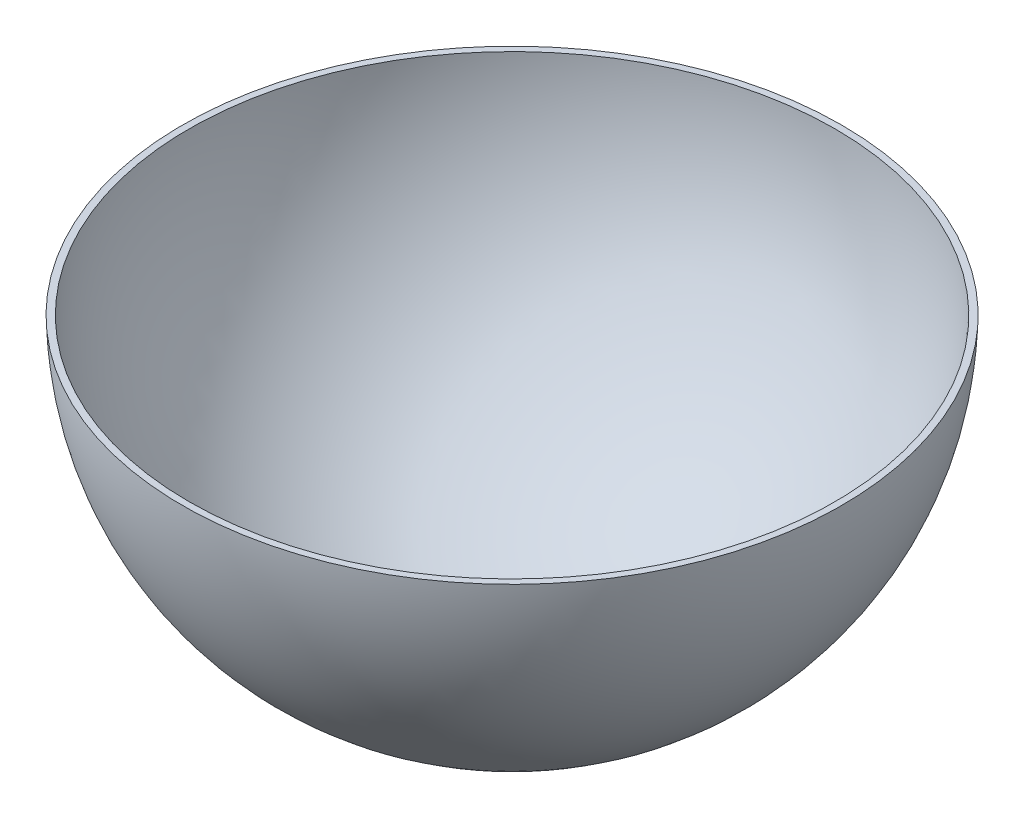
from build123d import *

# Parameters (mm, degrees)
SKETCH2_W               = 329.482175278
SKETCH2_H               = 165.618230588
CUT_EXTRUDE1_DEPTH      = 126
CUT_EXTRUDE1_DEPTH_BACK = 126


with BuildPart() as part:
    # Sketch1 one side → Revolve1 (revolve)
    with BuildSketch(Plane(origin=(0, 0, 0), x_dir=(0, 0, -1), z_dir=(1, 0, 0))):
        with BuildLine():
            ThreePointArc((0, -125), (88.388347648, -88.388347648), (125, 0))
            ThreePointArc((125, 0), (88.388347648, 88.388347648), (0, 125))
            Line((0, 125), (0, 122.5))
            ThreePointArc((0, 122.5), (86.620580695, 86.620580695), (122.5, 0))
            ThreePointArc((122.5, 0), (86.620580695, -86.620580695), (0, -122.5))
            Line((0, -122.5), (0, -125))
        make_face()
    revolve(axis=Axis((0, 125, 0), (0, -1, 0)))

    # Sketch2 → Cut-Extrude1 (cut, two sides)
    with BuildSketch(Plane.XY) as cut_extrude1_sk:
        with Locations((4.118527191, 79.6153008)):
            Rectangle(SKETCH2_W, SKETCH2_H)
    extrude(amount=CUT_EXTRUDE1_DEPTH, mode=Mode.SUBTRACT)
    extrude(cut_extrude1_sk.sketch, amount=-CUT_EXTRUDE1_DEPTH_BACK, mode=Mode.SUBTRACT)


solid = part.part
